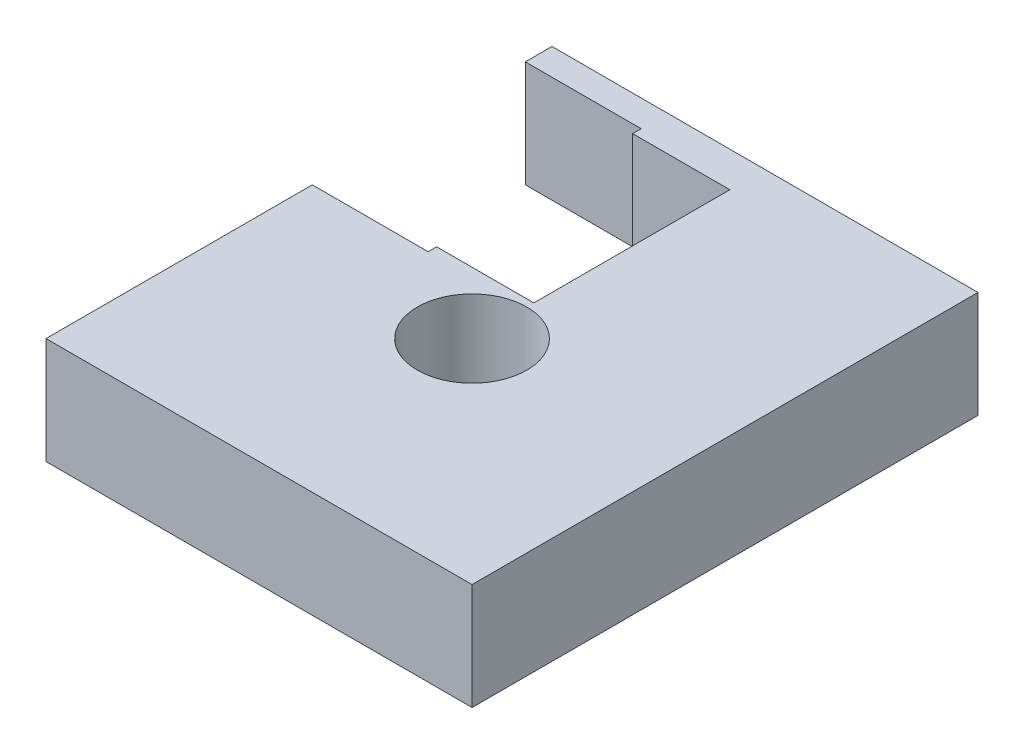
from build123d import *

# Parameters (mm, degrees)
BOSS_EXTRUDE1_DEPTH         = 6.35
F_1_4_CLEARANCE_HOLE1_D     = 6.5278
F_1_4_CLEARANCE_HOLE1_DEPTH = 6.35
F_1_4_CLEARANCE_HOLE1_TIP   = 1.961148974


with BuildPart() as part:
    # Sketch2 → Boss-Extrude1 (new body)
    with BuildSketch(Plane(origin=(0, 0, 0), x_dir=(1, 0, 0), z_dir=(0, 1, 0))):
        Polygon((-12.7, 15.875), (-12.7, 17.4625), (12.7, 17.4625), (12.7, -12.7), (-12.7, -12.7), (-12.7, 3.175), (-5.7912, 3.175), (-5.7912, 3.683), (0, 3.683), (0, 15.367), (-5.7912, 15.367), (-5.7912, 15.875), align=None)
    extrude(amount=BOSS_EXTRUDE1_DEPTH)

    # 1/4 Clearance Hole1
    with Locations(Plane(origin=(0, 6.35, 0), x_dir=(1, 0, 0), z_dir=(0, 1, 0))):
        with Locations((0, 0)):
            Hole(F_1_4_CLEARANCE_HOLE1_D / 2, depth=F_1_4_CLEARANCE_HOLE1_DEPTH)
            with Locations((0, 0, -(F_1_4_CLEARANCE_HOLE1_DEPTH + F_1_4_CLEARANCE_HOLE1_TIP / 2))):  # 118° drill point
                Cone(0, F_1_4_CLEARANCE_HOLE1_D / 2, F_1_4_CLEARANCE_HOLE1_TIP, mode=Mode.SUBTRACT)


solid = part.part
